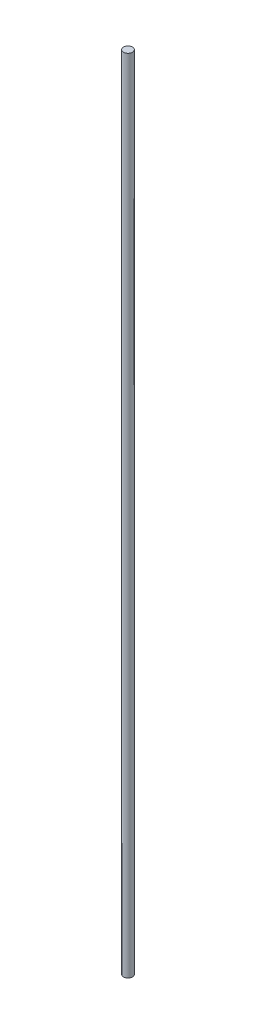
from build123d import *

# Parameters (mm, degrees)
SKETCH1_R           = 19.05
BOSS_EXTRUDE1_DEPTH = 3403.6


with BuildPart() as part:
    # Sketch1 → Boss-Extrude1 (new body)
    with BuildSketch(Plane(origin=(0, 0, 0), x_dir=(1, 0, 0), z_dir=(0, 1, 0))):
        Circle(SKETCH1_R)
    extrude(amount=BOSS_EXTRUDE1_DEPTH)


solid = part.part
